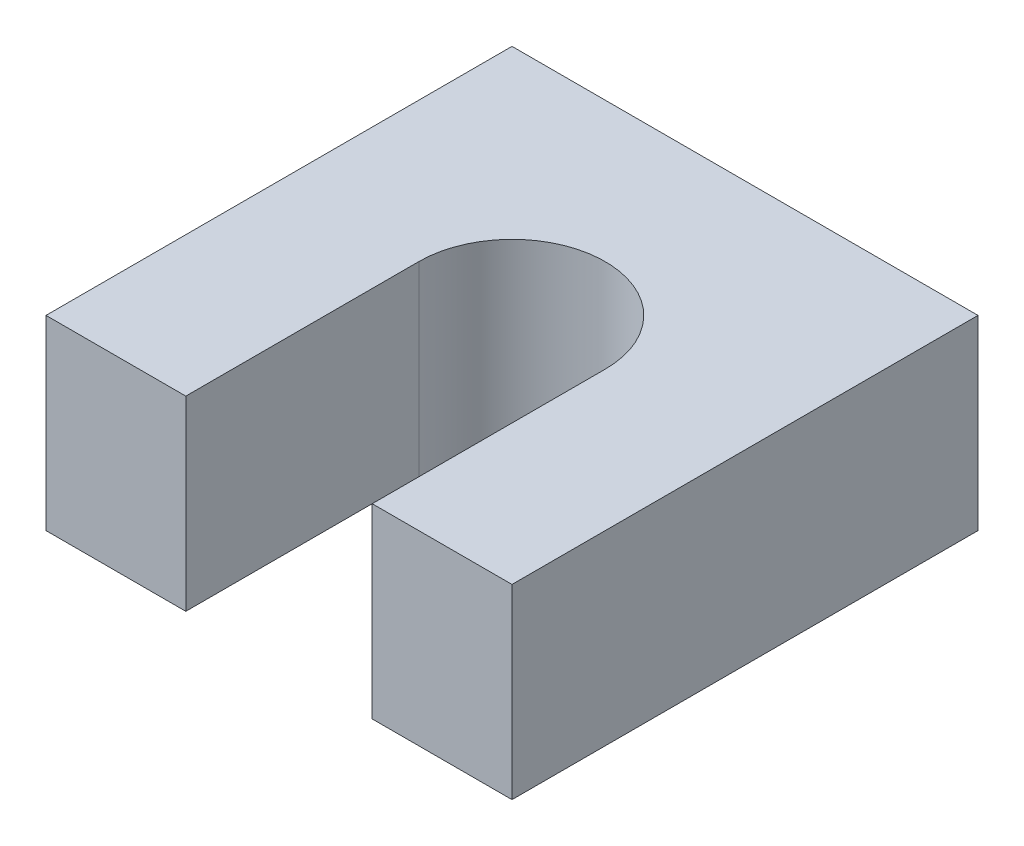
from build123d import *

# Parameters (mm, degrees)
BOSS_EXTRUDE1_DEPTH = 10.16


with BuildPart() as part:
    # Sketch1 → Boss-Extrude1 (new body)
    with BuildSketch(Plane(origin=(0, 0, 0), x_dir=(1, 0, 0), z_dir=(0, 1, 0))):
        with BuildLine():
            Line((-5.08, -12.7), (-5.08, 0))
            ThreePointArc((-5.08, 0), (0, 5.08), (5.08, 0))
            Line((5.08, 0), (5.08, -12.7))
            Line((5.08, -12.7), (12.7, -12.7))
            Line((12.7, -12.7), (12.7, 12.7))
            Line((12.7, 12.7), (-12.7, 12.7))
            Line((-12.7, 12.7), (-12.7, -12.7))
            Line((-12.7, -12.7), (-5.08, -12.7))
        make_face()
    extrude(amount=BOSS_EXTRUDE1_DEPTH)


solid = part.part
